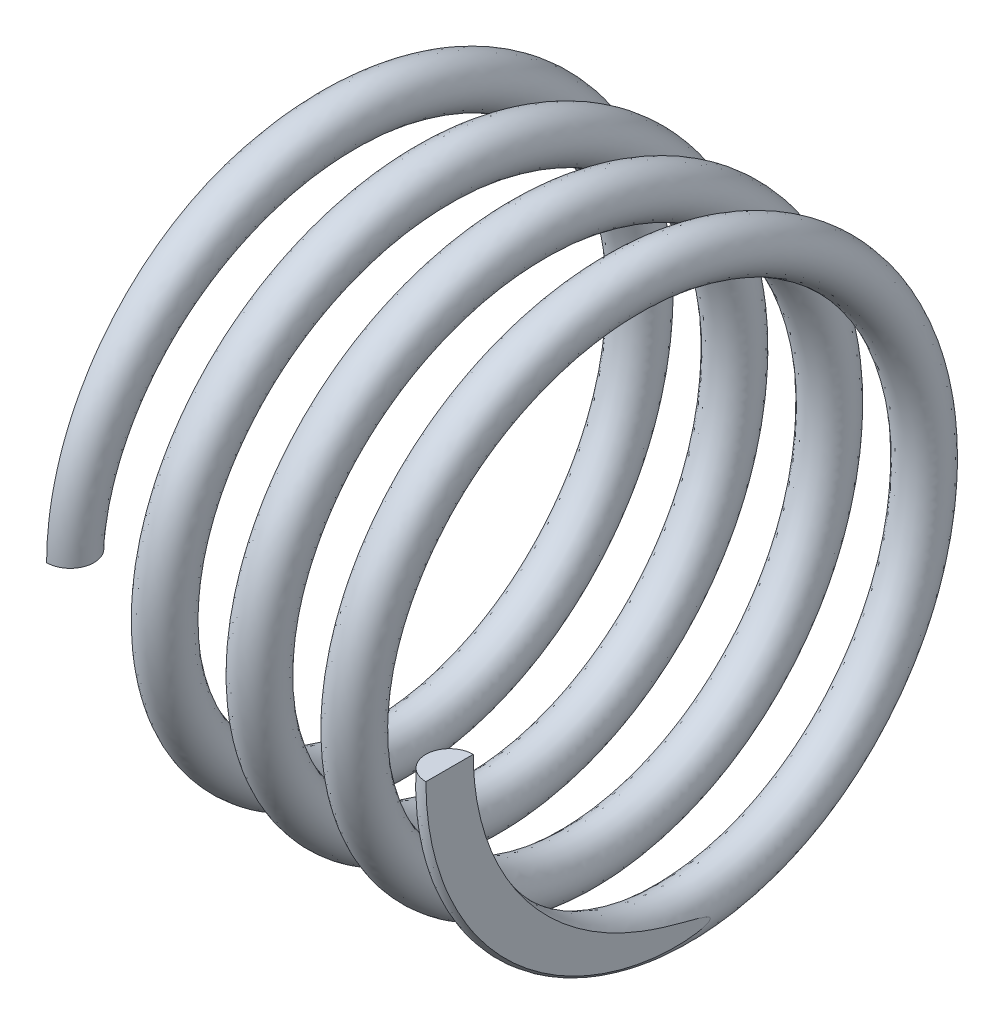
from build123d import *

# Parameters (mm, degrees)
SWEEP_1_PITCH       = 2
SWEEP_1_HEIGHT      = 8
SWEEP_1_RADIUS      = 5.5
SKETCH_3_R          = 0.5
SKETCH_6_W          = 2.252769002
SKETCH_6_H          = 6.363555562
CUT_EXTRUDE_2_DEPTH = 10
SKETCH_8_W          = 2.058208477
SKETCH_8_H          = 9.050899617
CUT_EXTRUDE_3_DEPTH = 10


with BuildPart() as part:
    # По траектории1: sweep along a helix
    with BuildLine() as sweep_1_path:
        Helix(SWEEP_1_PITCH, SWEEP_1_HEIGHT, SWEEP_1_RADIUS, center=(0, 0, 0), direction=(1, 0, 0), lefthand=True)
    # Эскиз3 → По траектории1 (sweep)
    with BuildSketch(Plane(origin=(0, 0, 0), x_dir=(1, 0, 0), z_dir=(0, 1, 0))):
        with Locations((8.001702786, -5.499139209)):
            Circle(SKETCH_3_R)
    sweep(path=sweep_1_path.line, is_frenet=True)

    # Эскиз6 → Вытянуть2 (cut)
    with BuildSketch(Plane(origin=(0, 0, 0), x_dir=(1, 0, 0), z_dir=(0, 1, 0))):
        with Locations((-1.124681715, -3.181777781)):
            Rectangle(SKETCH_6_W, SKETCH_6_H)
    extrude(amount=CUT_EXTRUDE_2_DEPTH, mode=Mode.SUBTRACT)

    # Эскиз8 → Вытянуть3 (cut)
    with BuildSketch(Plane(origin=(0, 0, 0), x_dir=(1, 0, 0), z_dir=(0, 1, 0))):
        with Locations((9.030807024, -1.4736894)):
            Rectangle(SKETCH_8_W, SKETCH_8_H)
    extrude(amount=-CUT_EXTRUDE_3_DEPTH, mode=Mode.SUBTRACT)


solid = part.part
